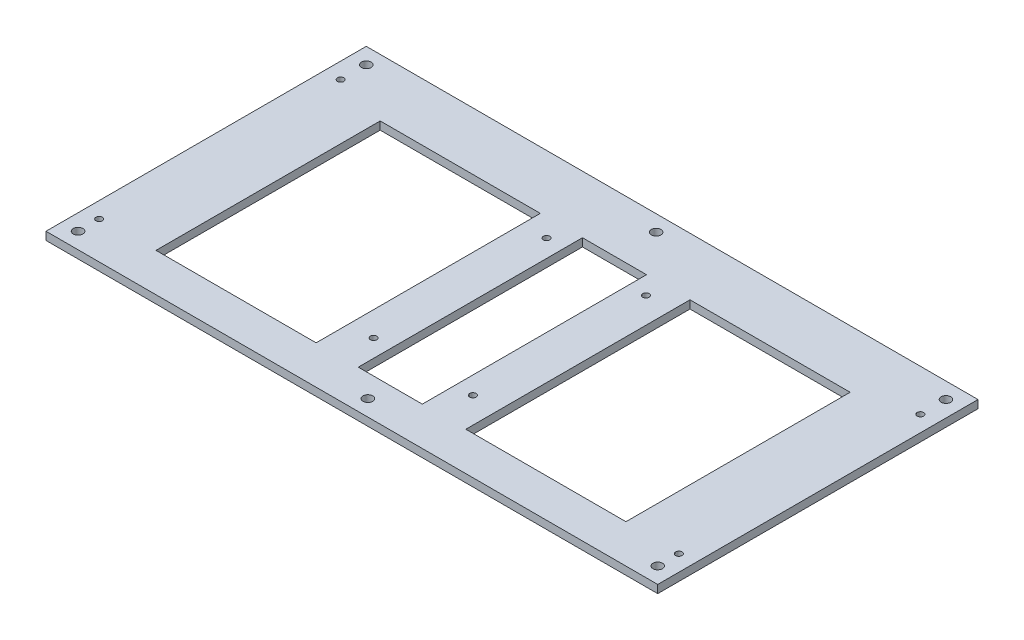
from build123d import *

# Parameters (mm, degrees)
SKETCH1_W           = 382
SKETCH1_H           = 200
BOSS_EXTRUDE5_DEPTH = 5
SKETCH7_R           = 2
CUT_EXTRUDE4_DEPTH  = 5
SKETCH8_W           = 40
SKETCH8_H           = 140
SKETCH8_W_2         = 100
CUT_EXTRUDE5_DEPTH  = 10
SKETCH9_R           = 3
CUT_EXTRUDE6_DEPTH  = 10


with BuildPart() as part:
    # Sketch1 → Boss-Extrude5 (new body)
    with BuildSketch(Plane(origin=(0, 0, 0), x_dir=(1, 0, 0), z_dir=(0, 1, 0))):
        with Locations((0, 6)):
            Rectangle(SKETCH1_W, SKETCH1_H)
    extrude(amount=BOSS_EXTRUDE5_DEPTH)

    # Sketch7 → Cut-Extrude4 (cut)
    with BuildSketch(Plane(origin=(0, 5, 0), x_dir=(1, 0, 0), z_dir=(0, 1, 0))):
        with Locations((181, 80)):
            Circle(SKETCH7_R)
        with Locations((181, -70.8)):
            Circle(SKETCH7_R)
        with Locations((31, 58.6)):
            Circle(SKETCH7_R)
        with Locations((-31, 58.6)):
            Circle(SKETCH7_R)
        with Locations((-181, 80)):
            Circle(SKETCH7_R)
        with Locations((-181, -70.8)):
            Circle(SKETCH7_R)
        with Locations((31, -49.4)):
            Circle(SKETCH7_R)
        with Locations((-31, -49.4)):
            Circle(SKETCH7_R)
    extrude(amount=-CUT_EXTRUDE4_DEPTH, mode=Mode.SUBTRACT)

    # Sketch8 → Cut-Extrude5 (cut)
    with BuildSketch(Plane(origin=(0, 5, 0), x_dir=(1, 0, 0), z_dir=(0, 1, 0))):
        Rectangle(SKETCH8_W, SKETCH8_H)
        with Locations((97.15487949, 0)):
            Rectangle(SKETCH8_W_2, SKETCH8_H)
        with Locations((-96.318135121, 0)):
            Rectangle(SKETCH8_W_2, SKETCH8_H)
    extrude(amount=-CUT_EXTRUDE5_DEPTH, mode=Mode.SUBTRACT)

    # Sketch9 → Cut-Extrude6 (cut)
    with BuildSketch(Plane(origin=(0, 5, 0), x_dir=(1, 0, 0), z_dir=(0, 1, 0))):
        with Locations((181, 96)):
            Circle(SKETCH9_R)
        with Locations((181, -84)):
            Circle(SKETCH9_R)
        with Locations((-181, 96)):
            Circle(SKETCH9_R)
        with Locations((-181, -84)):
            Circle(SKETCH9_R)
        with Locations((0, 96)):
            Circle(SKETCH9_R)
        with Locations((0, -84)):
            Circle(SKETCH9_R)
    extrude(amount=-CUT_EXTRUDE6_DEPTH, mode=Mode.SUBTRACT)


solid = part.part
